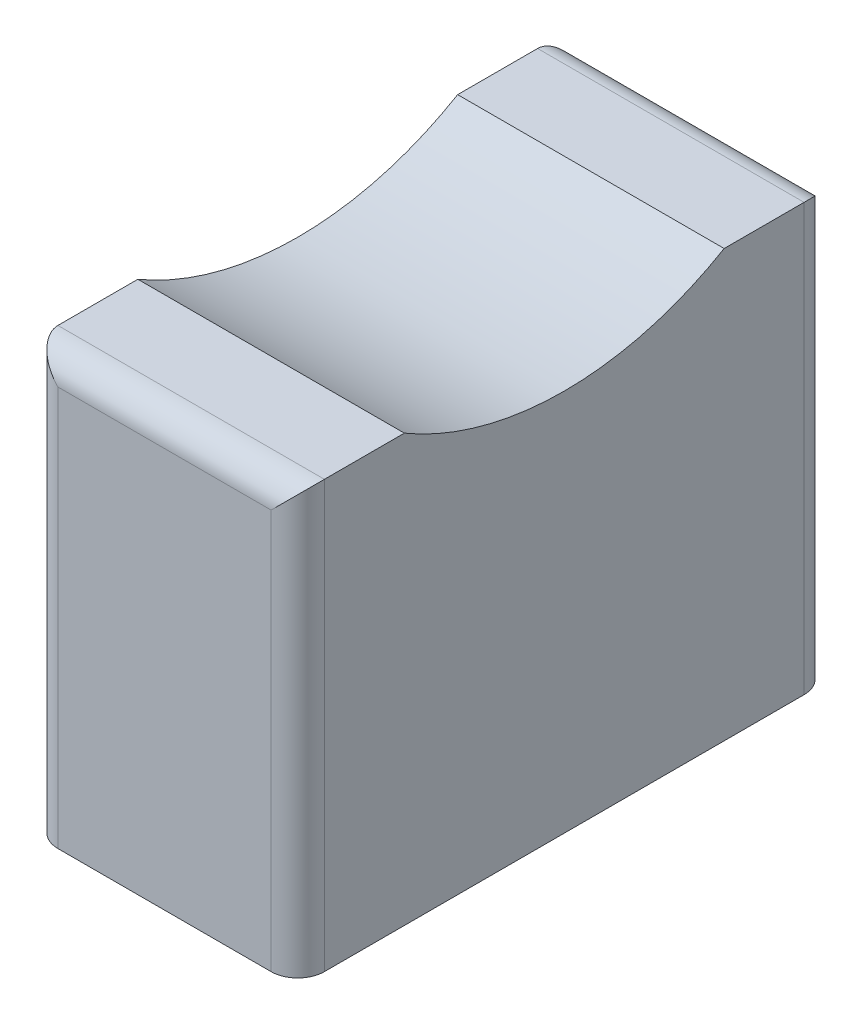
from build123d import *

# Parameters (mm, degrees)
SKETCH1_W           = 10
SKETCH1_H           = 20
BOSS_EXTRUDE1_DEPTH = 16
SKETCH2_W           = 1.4
SKETCH2_H           = 4.3
CUT_EXTRUDE1_DEPTH  = 5
CUT_EXTRUDE2_DEPTH  = 10
FILLET2_R           = 1


with BuildPart() as part:
    # Sketch1 → Boss-Extrude1 (new body)
    with BuildSketch(Plane(origin=(0, 0, 0), x_dir=(1, 0, 0), z_dir=(0, 1, 0))):
        Rectangle(SKETCH1_W, SKETCH1_H)
    extrude(amount=BOSS_EXTRUDE1_DEPTH)

    # Sketch2 → Cut-Extrude1 (cut)
    with BuildSketch(Plane.XZ):
        Rectangle(SKETCH2_W, SKETCH2_H)
    extrude(amount=-CUT_EXTRUDE1_DEPTH, mode=Mode.SUBTRACT)

    # Sketch6 → Cut-Extrude2 (cut)
    with BuildSketch(Plane(origin=(5, 0, 0), x_dir=(0, 0, -1), z_dir=(1, 0, 0))):
        with BuildLine():
            Line((-6, 16), (6, 16))
            ThreePointArc((6, 16), (0, 14.36598161), (-6, 16))
        make_face()
    extrude(amount=-CUT_EXTRUDE2_DEPTH, mode=Mode.SUBTRACT)

    # Fillet2
    fillet2_edges = [part.edges().sort_by_distance(p)[0] for p in [
        (0, 16, 10),
        (5, 8, 10),
        (-5, 8, 10),
        (-5, 8, -10),
        (5, 8, -10),
        (0, 16, -10),
    ]]
    fillet(fillet2_edges, radius=FILLET2_R)


solid = part.part
